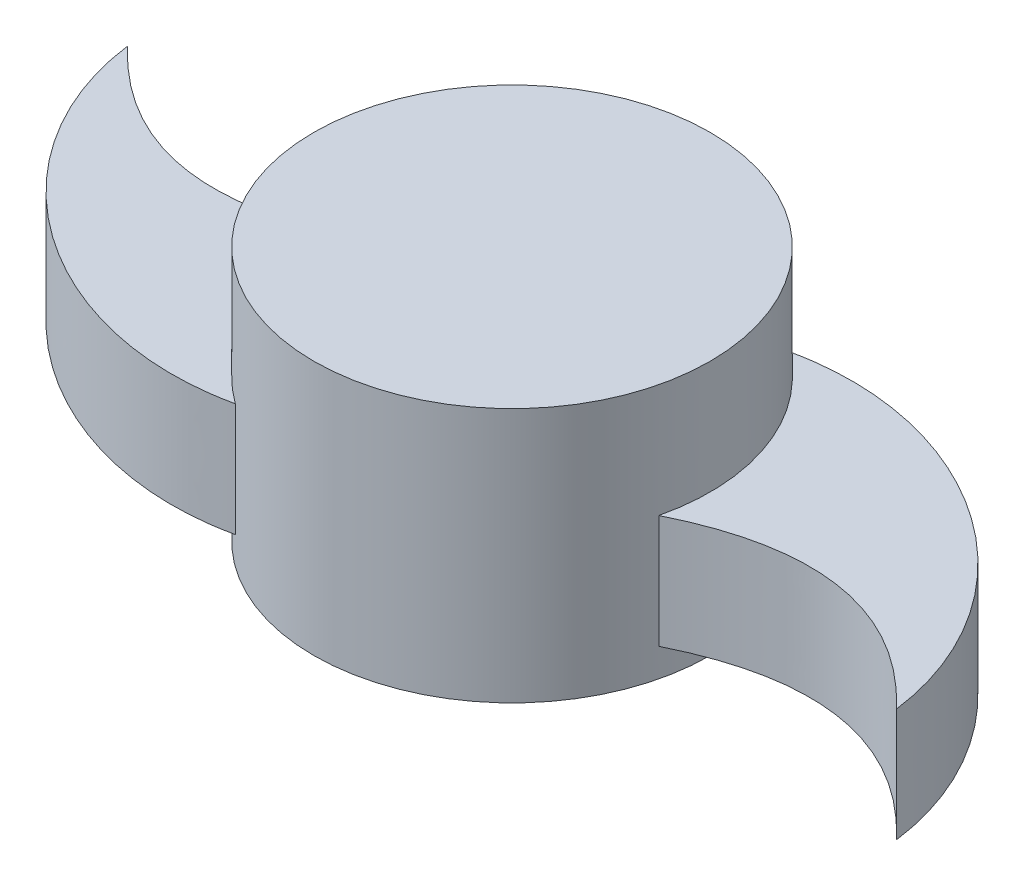
from build123d import *

# Parameters (mm, degrees)
SKETCH1_R           = 44.45
BOSS_EXTRUDE1_DEPTH = 57.15
BOSS_EXTRUDE2_DEPTH = 25.4


with BuildPart() as part:
    # Sketch1 → Boss-Extrude1 (new body)
    with BuildSketch(Plane(origin=(0, 0, 0), x_dir=(1, 0, 0), z_dir=(0, 1, 0))):
        Circle(SKETCH1_R)
    extrude(amount=BOSS_EXTRUDE1_DEPTH)

    # Sketch3 → Boss-Extrude2 (add)
    with BuildSketch(Plane(origin=(0, 6.35, 0), x_dir=(1, 0, 0), z_dir=(0, 1, 0))):
        with BuildLine():
            ThreePointArc((25.93836289, 36.097144355), (41.652954947, 15.518822255), (43.234152204, -10.325240105))
            add(Edge.make_bspline(
                [(107.47145922, -21.303368675), (79.942418966, 7.909262822), (43.234152204, -10.325240105)],
                knots=[0, 0, 0, 1, 1, 1], degree=2))
            add(Edge.make_bspline(
                [(25.93836289, 36.097144355), (62.849269779, 44.250068413), (102.789157255, 15.374374685), (107.47145922, -21.303368675)],
                knots=[0, 0, 0, 0, 1, 1, 1, 1], degree=3))
        make_face()
        with BuildLine():
            ThreePointArc((-25.93836289, -36.097144355), (-41.652954947, -15.518822255), (-43.234152204, 10.325240105))
            add(Edge.make_bspline(
                [(-107.47145922, 21.303368675), (-79.942418966, -7.909262822), (-43.234152204, 10.325240105)],
                knots=[0, 0, 0, 1, 1, 1], degree=2))
            add(Edge.make_bspline(
                [(-25.93836289, -36.097144355), (-62.849269779, -44.250068413), (-102.789157255, -15.374374685), (-107.47145922, 21.303368675)],
                knots=[0, 0, 0, 0, 1, 1, 1, 1], degree=3))
        make_face()
    extrude(amount=BOSS_EXTRUDE2_DEPTH)


solid = part.part
